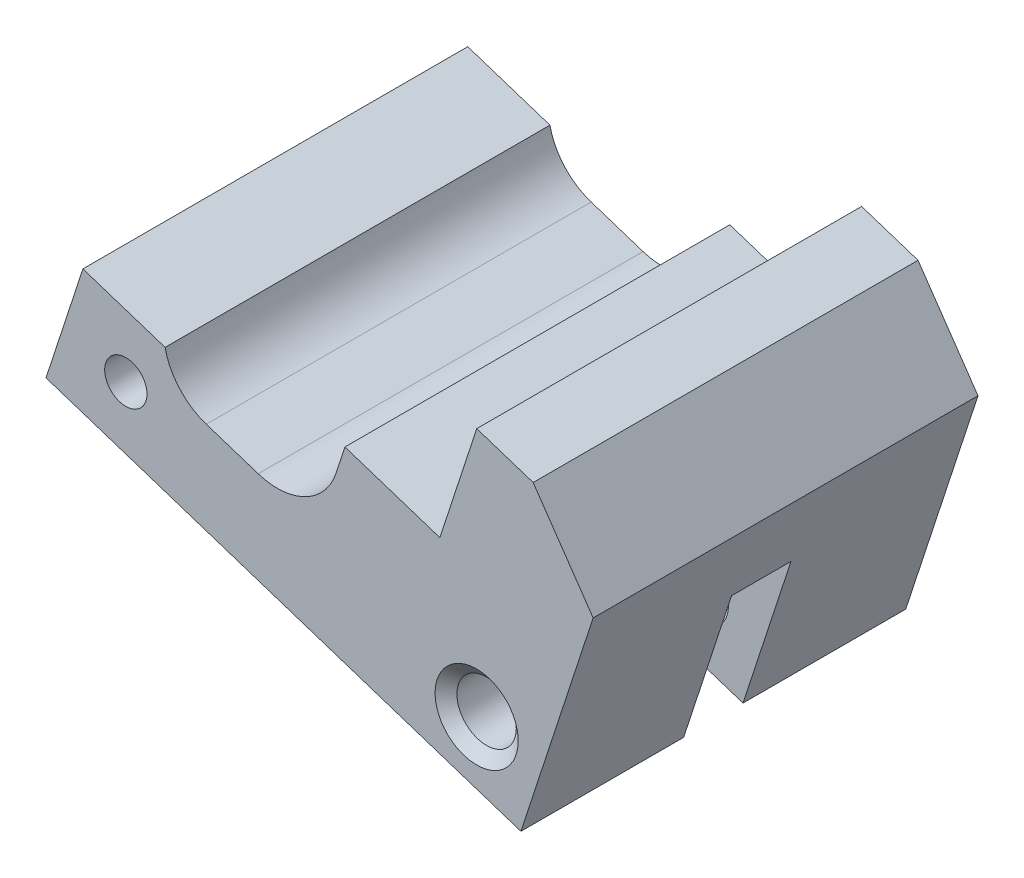
from build123d import *

# Parameters (mm, degrees)
BOSS_EXTRUDE1_START                    = 1.27
BOSS_EXTRUDE1_DEPTH                    = 20.586143
F_4_40_TAPPED_HOLE1_D                  = 2.2606
F_1_8_0_125_DIAMETER_HOLE1_D           = 3.175
F_1_8_0_125_DIAMETER_HOLE1_CSINK_D     = 4.445
F_1_8_0_125_DIAMETER_HOLE1_CSINK_ANGLE = 100
CUT_EXTRUDE1_DEPTH                     = 8.255
CUT_EXTRUDE2_DEPTH                     = 21.586143296


with BuildPart() as part:
    # Sketch1 → Boss-Extrude1 (new body)
    with BuildSketch(Plane.XY.offset(BOSS_EXTRUDE1_START)):
        Polygon((8.016705611, -68.938838733), (7.029985744, -71.956620849), (0.99442151, -69.983181117), (0.007701644, -73.000963234), (-12.063426824, -69.054083768), (-14.036866557, -75.089648002), (11.365311403, -83.395361493), (15.229120806, -71.578294343), (12.021207594, -66.907776482), (9.003425477, -65.921056616), align=None)
    extrude(amount=BOSS_EXTRUDE1_DEPTH)

    # #4-40 Tapped Hole1 (through all)
    with Locations(Plane.XY.offset(21.856143296)):
        with Locations((-9.766799747, -73.145417099)):
            Hole(F_4_40_TAPPED_HOLE1_D / 2)

    # 1/8 (0.125) Diameter Hole1 (through all)
    with Locations(Plane.XY.offset(21.856143296)):
        with Locations((8.997580837, -79.280779556)):
            CounterSinkHole(F_1_8_0_125_DIAMETER_HOLE1_D / 2, F_1_8_0_125_DIAMETER_HOLE1_CSINK_D / 2, counter_sink_angle=F_1_8_0_125_DIAMETER_HOLE1_CSINK_ANGLE)

    # Sketch6 → Cut-Extrude1 (cut)
    with BuildSketch(Plane(origin=(-23.536376178, -71.983607041, 0), x_dir=(0.950482557, -0.310777911, 0), z_dir=(-0.310777911, -0.950482557, 0))):
        with BuildLine():
            Line((36.719966444, 13.150571648), (26.559966444, 13.150571648))
            ThreePointArc((26.559966444, 13.150571648), (24.972466444, 11.563071648), (26.559966444, 9.975571648))
            Line((26.559966444, 9.975571648), (36.719966444, 9.975571648))
            ThreePointArc((36.719966444, 9.975571648), (38.307466444, 11.563071648), (36.719966444, 13.150571648))
        make_face()
    extrude(amount=-CUT_EXTRUDE1_DEPTH, mode=Mode.SUBTRACT)

    # Sketch8 → Cut-Extrude2 (cut, through all)
    with BuildSketch(Plane.XY.offset(21.856143296)):
        with BuildLine():
            Line((-5.462102823, -72.94952157), (-2.685743275, -73.857303847))
            ThreePointArc((-2.685743275, -73.857303847), (-0.165929608, -73.663685373), (1.478938787, -71.744999106))
            ThreePointArc((1.478938787, -71.744999106), (1.632876898, -70.97000506), (1.598291814, -70.180627719))
            Line((1.598291814, -70.180627719), (0.99442151, -69.983181117))
            Line((0.99442151, -69.983181117), (0.007701644, -73.000963234))
            Line((0.007701644, -73.000963234), (-7.667023508, -70.491569419))
            ThreePointArc((-7.667023508, -70.491569419), (-6.893866312, -72.015948853), (-5.462102823, -72.94952157))
        make_face()
        with BuildLine():
            ThreePointArc((1.598291814, -70.180627719), (1.632876898, -70.97000506), (1.478938787, -71.744999106))
            Line((1.478938787, -71.744999106), (1.952564323, -70.29646369))
            Line((1.952564323, -70.29646369), (1.598291814, -70.180627719))
        make_face()
    extrude(amount=-CUT_EXTRUDE2_DEPTH, mode=Mode.SUBTRACT)


solid = part.part
